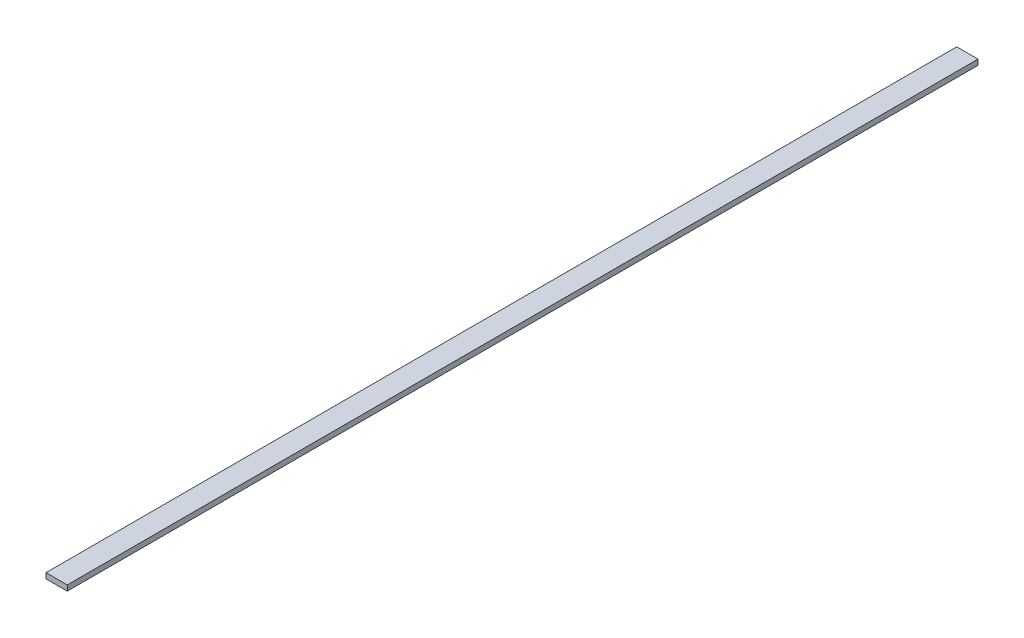
from build123d import *

# Parameters (mm, degrees)
SKETCH1_W           = 21.6
SKETCH1_H           = 5.5
BOSS_EXTRUDE1_DEPTH = 925


with BuildPart() as part:
    # Sketch1 → Boss-Extrude1 (new body)
    with BuildSketch(Plane.XY):
        with Locations((10.8, 2.75)):
            Rectangle(SKETCH1_W, SKETCH1_H)
    extrude(amount=BOSS_EXTRUDE1_DEPTH)


solid = part.part
